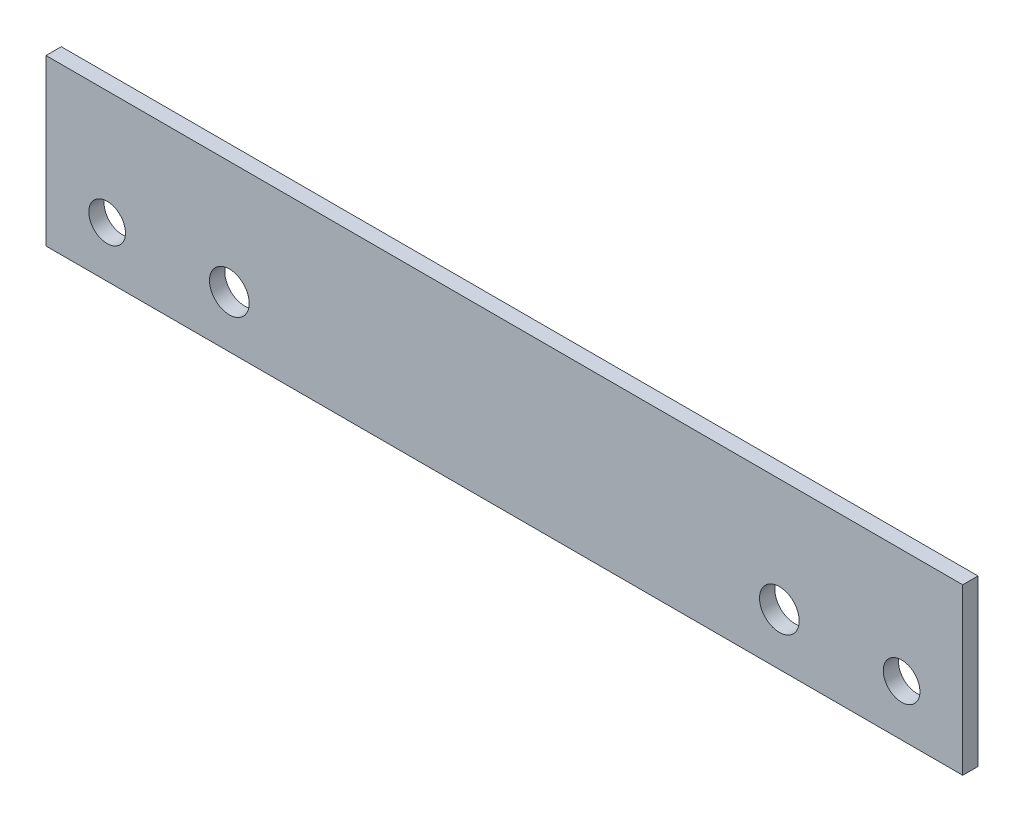
from build123d import *

# Parameters (mm, degrees)
SKETCH_1_W          = 300
SKETCH_1_H          = 54
EXTRUDE_1_DEPTH     = 5
SKETCH_2_R          = 6
CUT_EXTRUDE_1_DEPTH = 6
SKETCH_3_R          = 6.5
CUT_EXTRUDE_2_DEPTH = 10


with BuildPart() as part:
    # 草图1 → 凸台-拉伸1 (new body)
    with BuildSketch(Plane.XY):
        Rectangle(SKETCH_1_W, SKETCH_1_H)
    extrude(amount=EXTRUDE_1_DEPTH)

    # 草图2 → 切除-拉伸1 (cut, through all)
    with BuildSketch(Plane(origin=(0, 0, 0), x_dir=(-1, 0, 0), z_dir=(0, 0, -1))):
        with Locations((-130, -10.3)):
            Circle(SKETCH_2_R)
    cut_extrude_1 = extrude(amount=-CUT_EXTRUDE_1_DEPTH, mode=Mode.SUBTRACT)

    # 镜向1: 切除-拉伸1 across plane
    add(cut_extrude_1.mirror(Plane(origin=(0, 0, 0), x_dir=(0, 0, 1), z_dir=(1, 0, 0))), mode=Mode.SUBTRACT)

    # 草图3 → 切除-拉伸2 (cut)
    with BuildSketch(Plane(origin=(0, 0, 0), x_dir=(-1, 0, 0), z_dir=(0, 0, -1))):
        with Locations((-90, -10)):
            Circle(SKETCH_3_R)
    cut_extrude_2 = extrude(amount=-CUT_EXTRUDE_2_DEPTH, mode=Mode.SUBTRACT)

    # 镜向2: 切除-拉伸2 across plane
    add(cut_extrude_2.mirror(Plane(origin=(0, 0, 0), x_dir=(0, 0, 1), z_dir=(1, 0, 0))), mode=Mode.SUBTRACT)


solid = part.part
